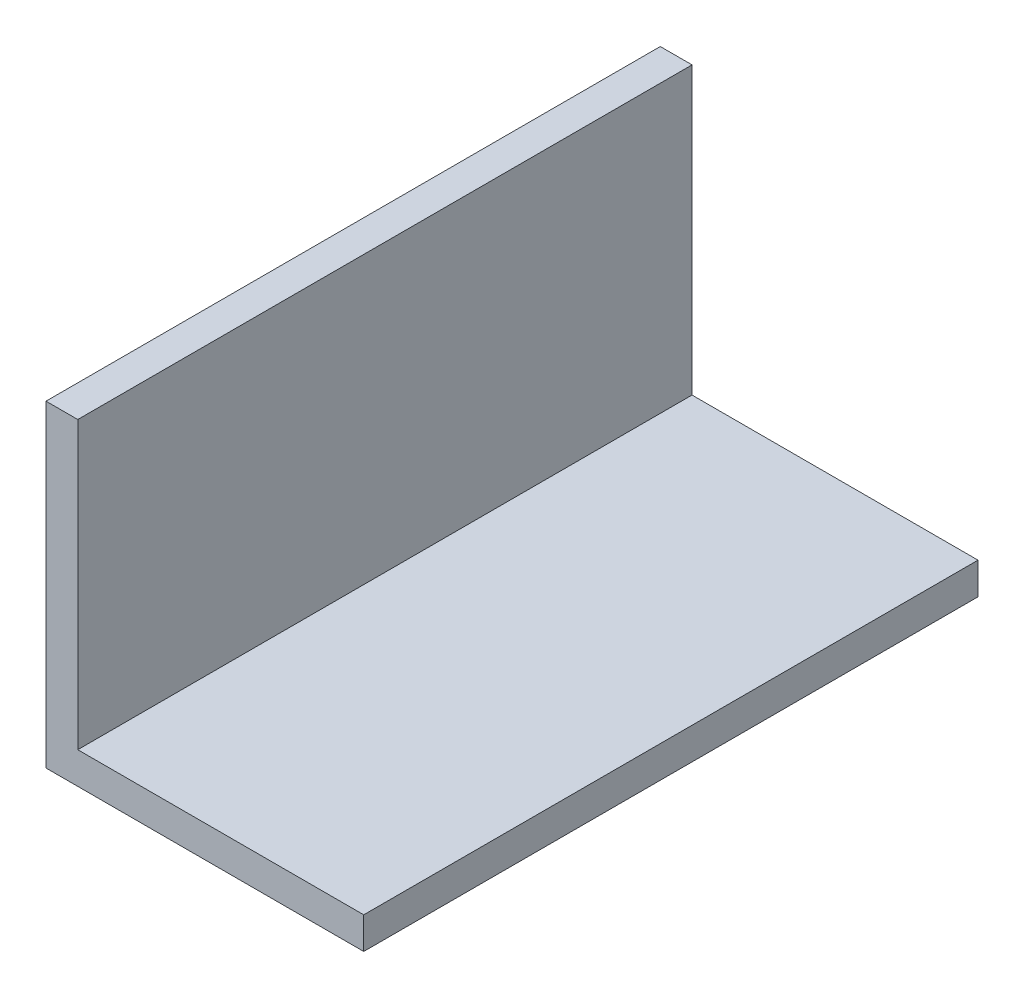
from build123d import *

# Parameters (mm, degrees)
EXTRUDE_1_DEPTH = 58


with BuildPart() as part:
    # Эскиз1 → Бобышка-Вытянуть1 (new body)
    with BuildSketch(Plane.XY):
        Polygon((0, 30), (0, 0), (30, 0), (30, 3), (3, 3), (3, 30), align=None)
    extrude(amount=EXTRUDE_1_DEPTH)


solid = part.part
